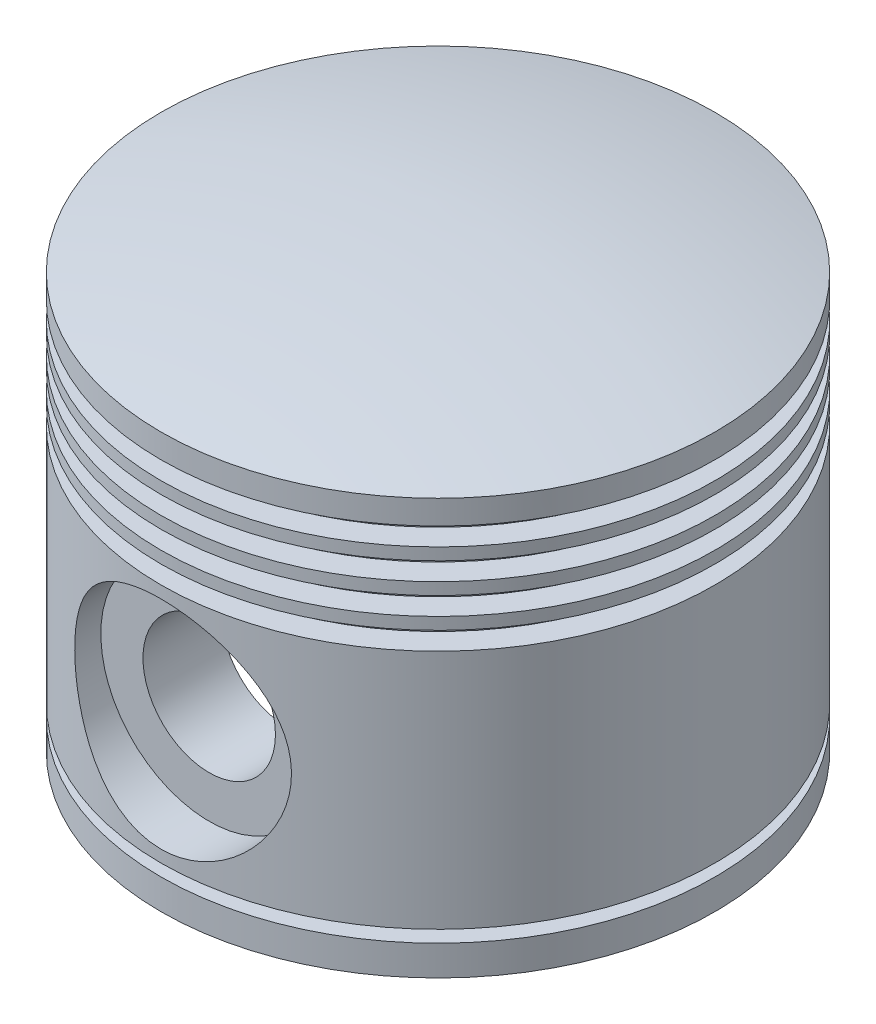
from build123d import *

# Parameters (mm, degrees)
SKETCH19_R              = 11
CUT_EXTRUDE4_DEPTH      = 47
CUT_EXTRUDE4_DEPTH_BACK = 47
CUT_EXTRUDE5_START      = 38
SKETCH20_R              = 18
CUT_EXTRUDE5_DEPTH      = 51.0000001
BOSS_EXTRUDE2_START     = -37
SKETCH21_R              = 18
SKETCH21_R_2            = 11
BOSS_EXTRUDE2_DEPTH     = 12


with BuildPart() as part:
    # Sketch1 → Revolve1 (revolve)
    with BuildSketch(Plane.XY):
        with BuildLine():
            Line((-46, 0), (-46, 5))
            Line((-46, 5), (-42, 5))
            Line((-42, 5), (-42, 7))
            Line((-42, 7), (-46, 7))
            Line((-46, 7), (-46, 9))
            Line((-46, 9), (-46, 45))
            Line((-46, 45), (-46, 47))
            Line((-46, 47), (-42, 47))
            Line((-42, 47), (-42, 50))
            Line((-42, 50), (-46, 50))
            Line((-46, 50), (-46, 52))
            Line((-46, 52), (-42, 52))
            Line((-42, 52), (-42, 55))
            Line((-42, 55), (-46, 55))
            Line((-46, 55), (-46, 57))
            Line((-46, 57), (-42, 57))
            Line((-42, 57), (-42, 60))
            Line((-42, 60), (-46, 60))
            Line((-46, 60), (-46, 62))
            Line((-46, 62), (-42, 62))
            Line((-42, 62), (-42, 65))
            Line((-42, 65), (-46, 65))
            Line((-46, 65), (-46, 69))
            ThreePointArc((-46, 69), (-23.174880185, 73.257119382), (0, 74.683334091))
            Line((0, 74.683334091), (0, 69))
            Line((0, 69), (0, 60))
            Line((0, 60), (-37, 60))
            Line((-37, 60), (-37, 47))
            Line((-37, 47), (-37, 9))
            Line((-37, 9), (-37, 0))
            Line((-37, 0), (-46, 0))
        make_face()
    revolve(axis=Axis((0, 165.443928378, 0), (0, -1, 0)))

    # Sketch19 → Cut-Extrude4 (cut, two sides)
    with BuildSketch(Plane.XY) as cut_extrude4_sk:
        with Locations((0, 27)):
            Circle(SKETCH19_R)
    extrude(amount=CUT_EXTRUDE4_DEPTH, mode=Mode.SUBTRACT)
    extrude(cut_extrude4_sk.sketch, amount=-CUT_EXTRUDE4_DEPTH_BACK, mode=Mode.SUBTRACT)

    # Sketch20 → Cut-Extrude5 (cut)
    with BuildSketch(Plane.XY.offset(CUT_EXTRUDE5_START)):
        with Locations((0, 27)):
            Circle(SKETCH20_R)
    cut_extrude5 = extrude(amount=CUT_EXTRUDE5_DEPTH, mode=Mode.SUBTRACT)

    # Mirror1: Cut-Extrude5 across plane
    add(cut_extrude5.mirror(Plane.XY), mode=Mode.SUBTRACT)

    # Sketch21 → Boss-Extrude2 (add)
    with BuildSketch(Plane.XY.offset(BOSS_EXTRUDE2_START)):
        with Locations((0, 27)):
            Circle(SKETCH21_R)
        with Locations((0, 27)):
            Circle(SKETCH21_R_2, mode=Mode.SUBTRACT)
    boss_extrude2 = extrude(amount=BOSS_EXTRUDE2_DEPTH)

    # Mirror2: Boss-Extrude2 across plane
    add(boss_extrude2.mirror(Plane.XY))


solid = part.part
